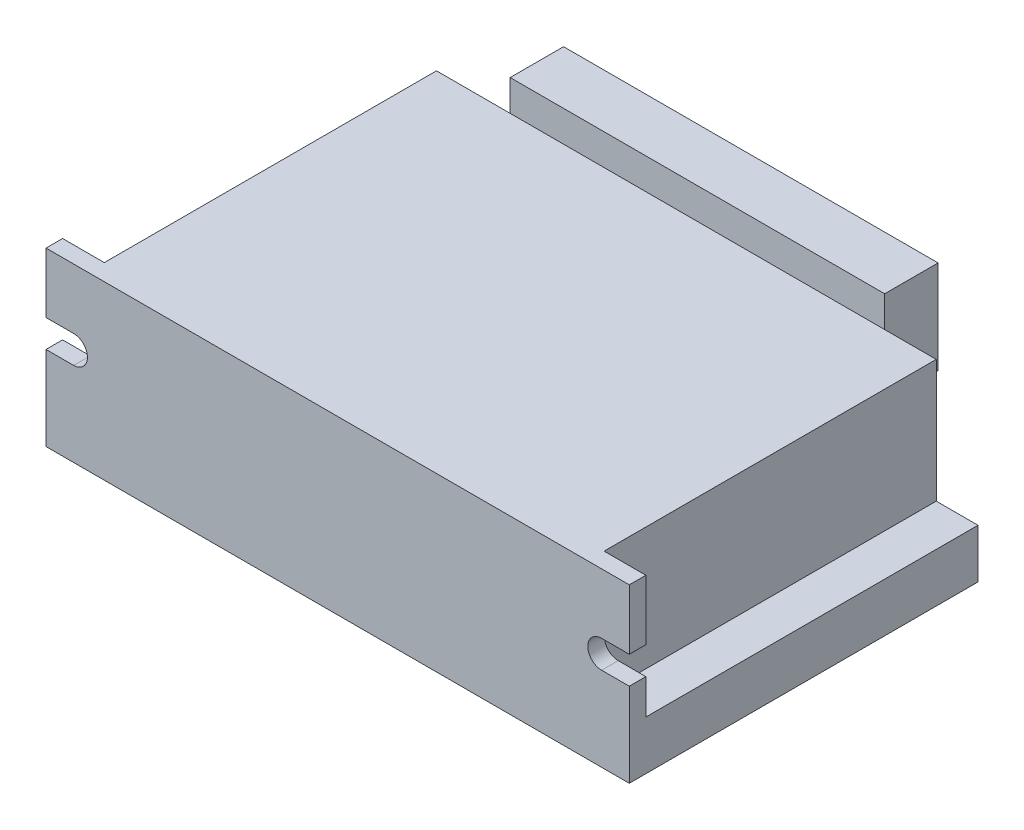
from build123d import *

# Parameters (mm, degrees)
EXTRUDE_1_DEPTH     = 95
SKETCH_2_W          = 81.4
SKETCH_2_H          = 54.1
EXTRUDE_2_DEPTH     = 20
SKETCH_3_W          = 61
SKETCH_3_H          = 8
EXTRUDE_3_DEPTH     = 13
SKETCH_4_W          = 61
SKETCH_4_H          = 8.7
EXTRUDE_4_DEPTH     = 7.2
CUT_EXTRUDE_1_DEPTH = 70.8


with BuildPart() as part:
    # 草图1 → 凸台-拉伸1 (new body)
    with BuildSketch(Plane(origin=(0, 0, 0), x_dir=(0, 0, -1), z_dir=(1, 0, 0))):
        Polygon((0, 0), (-56.8, 0), (-56.8, 28), (-54.1, 28), (-54.1, 8), (0, 8), align=None)
    extrude(amount=EXTRUDE_1_DEPTH)

    # 草图2 → 凸台-拉伸2 (add)
    with BuildSketch(Plane(origin=(0, 8, 0), x_dir=(1, 0, 0), z_dir=(0, 1, 0))):
        with Locations((47.5, -27.05)):
            Rectangle(SKETCH_2_W, SKETCH_2_H)
    extrude(amount=EXTRUDE_2_DEPTH)

    # 草图3 → 凸台-拉伸3 (add)
    with BuildSketch(Plane(origin=(0, 0, 0), x_dir=(-1, 0, 0), z_dir=(0, 0, -1))):
        with Locations((-45, 17.553614205)):
            Rectangle(SKETCH_3_W, SKETCH_3_H)
    extrude(amount=EXTRUDE_3_DEPTH)

    # 草图4 → 凸台-拉伸4 (add)
    with BuildSketch(Plane(origin=(0, 21.553614205, 0), x_dir=(1, 0, 0), z_dir=(0, 1, 0))):
        with Locations((45, 8.65)):
            Rectangle(SKETCH_4_W, SKETCH_4_H)
    extrude(amount=EXTRUDE_4_DEPTH)

    # 草图7 → 切除-拉伸1 (cut, through all)
    with BuildSketch(Plane.XY.offset(56.8)):
        with BuildLine():
            Line((4.5, 18.2), (0, 18.2))
            Line((0, 18.2), (0, 13.7))
            Line((0, 13.7), (4.5, 13.7))
            ThreePointArc((4.5, 13.7), (6.75, 15.95), (4.5, 18.2))
        make_face()
        with BuildLine():
            Line((90.5, 13.7), (95, 13.7))
            Line((95, 13.7), (95, 18.2))
            Line((95, 18.2), (90.5, 18.2))
            ThreePointArc((90.5, 18.2), (88.25, 15.95), (90.5, 13.7))
        make_face()
    extrude(amount=-CUT_EXTRUDE_1_DEPTH, mode=Mode.SUBTRACT)


solid = part.part
